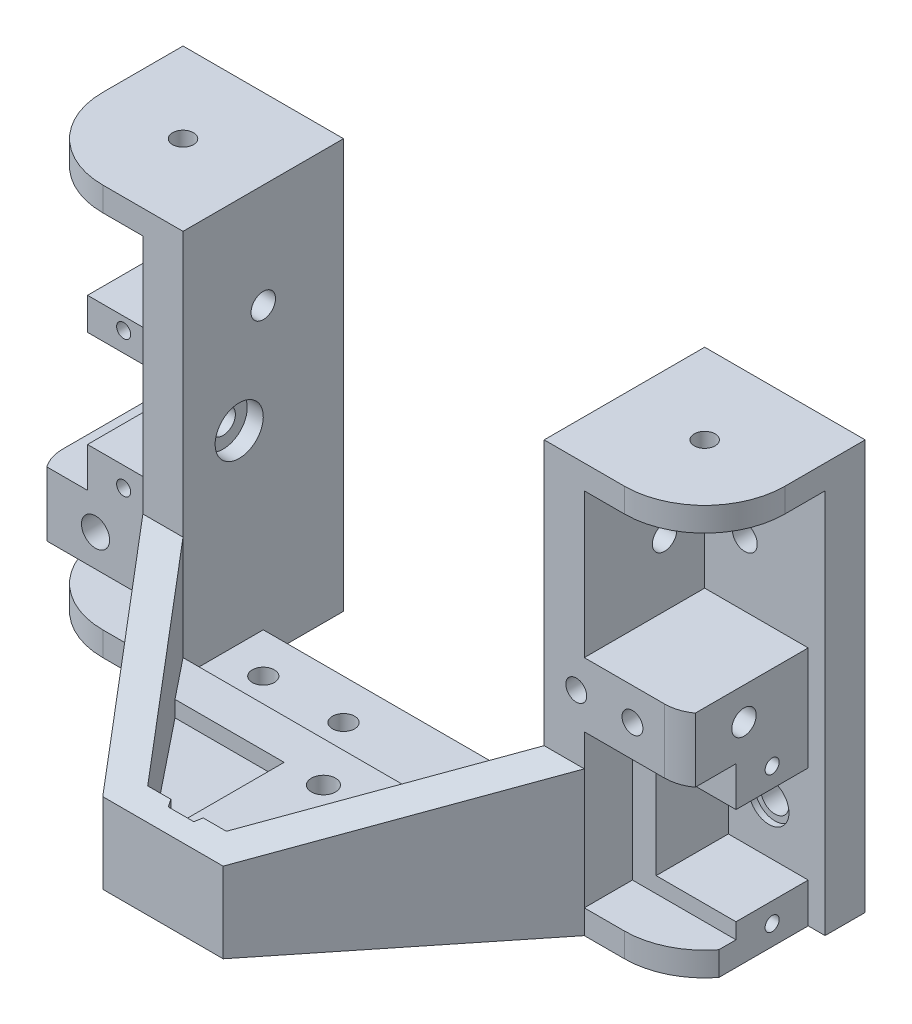
from build123d import *

# Parameters (mm, degrees)
SKETCH1_R                 = 1.75
SKETCH1_R_2               = 1.55
MAIN_FLANGE_DEPTH         = 5
SKETCH2_W                 = 15
SKETCH2_H                 = 45
SKETCH2_R                 = 1.525
SIDE_FLANGE_DEPTH         = 5
SKETCH11_R                = 1.3
BOSS_EXTRUDE3_DEPTH       = 3
BOSS_EXTRUDE4_DEPTH       = 7
SKETCH16_R                = 1.3
TOP_SUPPORT_DEPTH         = 3
SKETCH18_W                = 15
SKETCH18_H                = 8
SKETCH18_R                = 1.525
BOSS_EXTRUDE5_DEPTH       = 15
SKETCH19_W                = 15
SKETCH19_H                = 8
SKETCH19_R                = 1.75
BOSS_EXTRUDE6_DEPTH       = 15
FILLET1_R                 = 5
M3X0_5_TAPPED_HOLE1_D     = 2.6
M3X0_5_TAPPED_HOLE1_DEPTH = 7.5
M3X0_5_TAPPED_HOLE1_TIP   = 0.781118805
M3X0_5_TAPPED_HOLE2_D     = 2.6
M3X0_5_TAPPED_HOLE2_DEPTH = 7.5
M3X0_5_TAPPED_HOLE2_TIP   = 0.781118805
SKETCH24_R                = 2.5
CUT_EXTRUDE1_DEPTH        = 0.75
SKETCH25_R                = 2.5
CUT_EXTRUDE2_DEPTH        = 0.75
SKETCH26_W                = 10
SKETCH26_H                = 2.85
BOSS_EXTRUDE7_DEPTH       = 10
MOTOR_MOUNT_DEPTH         = 9
SKETCH33_W                = 15
SKETCH33_H                = 30
CUT_EXTRUDE6_DEPTH        = 2.1
SKETCH34_R                = 0.875
CUT_EXTRUDE7_DEPTH        = 7
BOSS_EXTRUDE9_DEPTH       = 9
SKETCH36_W                = 15
SKETCH36_H                = 29.05
CUT_EXTRUDE8_DEPTH        = 2.1
SKETCH37_R                = 0.875
CUT_EXTRUDE9_DEPTH        = 7
SKETCH39_W                = 45
SKETCH39_H                = 10
CUT_EXTRUDE11_DEPTH       = 52
SKETCH40_R                = 1.375
MOUNT_HOLES_DEPTH         = 4.0000001
SKETCH41_R                = 3
BEARING_HOLDER_DEPTH      = 2
SKETCH42_R                = 3
CUT_EXTRUDE14_DEPTH       = 2
BOSS_EXTRUDE10_DEPTH      = 3
BOSS_EXTRUDE11_DEPTH      = 15
CUT_EXTRUDE15_DEPTH       = 43.5
CUT_EXTRUDE15_DEPTH_BACK  = 43.5000001
BOSS_EXTRUDE12_DEPTH      = 2
CUT_EXTRUDE16_REACH       = 53
SKETCH48_R                = 1.5
CUT_EXTRUDE17_DEPTH       = 47


with BuildPart() as part:
    # Sketch1 → main flange (new body)
    with BuildSketch(Plane.XY):
        Polygon((-22.5, 7), (0, 7), (22.5, 7), (22.5, 45), (42.5, 45), (42.5, 0), (-42.5, 0), (-42.5, 45), (-22.5, 45), align=None)
        with Locations((35.5, 8)):
            Circle(SKETCH1_R, mode=Mode.SUBTRACT)
        with Locations((-35.5, 8)):
            Circle(SKETCH1_R, mode=Mode.SUBTRACT)
        with Locations((32.5, 35)):
            Circle(SKETCH1_R_2, mode=Mode.SUBTRACT)
        with Locations((-32.5, 35)):
            Circle(SKETCH1_R_2, mode=Mode.SUBTRACT)
    extrude(amount=MAIN_FLANGE_DEPTH)

    # Sketch2 → side flange (add)
    with BuildSketch(Plane(origin=(22.5, 0, 0), x_dir=(0, 0, -1), z_dir=(1, 0, 0))):
        with Locations((-12.5, 22.5)):
            Rectangle(SKETCH2_W, SKETCH2_H)
        with Locations((-13, 23)):
            Circle(SKETCH2_R, mode=Mode.SUBTRACT)
        with Locations((-10, 35)):
            Circle(SKETCH2_R, mode=Mode.SUBTRACT)
    side_flange = extrude(amount=SIDE_FLANGE_DEPTH)

    # Mirror1: side flange across plane
    add(side_flange.mirror(Plane(origin=(0, 0, 0), x_dir=(0, 0, 1), z_dir=(1, 0, 0))))

    # Sketch11 → Boss-Extrude3 (add)
    with BuildSketch(Plane.XZ):
        with BuildLine():
            Line((-42.5, 0), (42.5, 0))
            Line((42.5, 0), (42.5, 10))
            ThreePointArc((42.5, 10), (39.571067812, 17.071067812), (32.5, 20))
            Line((32.5, 20), (-32.5, 20))
            ThreePointArc((-32.5, 20), (-39.571067812, 17.071067812), (-42.5, 10))
            Line((-42.5, 10), (-42.5, 0))
        make_face()
        with Locations((-32.5, 10)):
            Circle(SKETCH11_R, mode=Mode.SUBTRACT)
        with Locations((32.5, 10)):
            Circle(SKETCH11_R, mode=Mode.SUBTRACT)
    extrude(amount=BOSS_EXTRUDE3_DEPTH)

    # Sketch12 → Boss-Extrude4 (add)
    with BuildSketch(Plane(origin=(0, 0, 0), x_dir=(1, 0, 0), z_dir=(0, 1, 0))):
        with BuildLine():
            Line((-4, -3), (-4, 0))
            Line((-4, 0), (4, 0))
            Line((4, 0), (4, -3))
            ThreePointArc((4, -3), (0, -7), (-4, -3))
        make_face()
    extrude(amount=BOSS_EXTRUDE4_DEPTH)

    # Sketch15 → CSK for M3 Flat Head Machine Screw1 (revolve, cut)
    with BuildSketch(Plane(origin=(0, -3, 3), x_dir=(0, 0, -1), z_dir=(1, 0, 0))):
        Polygon((0, 0), (0, 10), (1.8, 10), (1.8, 1.5), (3.15, 0.15), (3.15, 0), align=None)
    revolve(axis=Axis((0, -9.35, 3), (0, 1, 0)), mode=Mode.SUBTRACT)

    # Sketch16 → Top support (add)
    with BuildSketch(Plane(origin=(0, 45, 0), x_dir=(1, 0, 0), z_dir=(0, 1, 0))):
        with BuildLine():
            Line((-42.5, 0), (-22.5, 0))
            Line((-22.5, 0), (-22.5, -20))
            Line((-22.5, -20), (-32.5, -20))
            ThreePointArc((-32.5, -20), (-39.571067812, -17.071067812), (-42.5, -10))
            Line((-42.5, -10), (-42.5, 0))
        make_face()
        with Locations((-32.5, -10)):
            Circle(SKETCH16_R, mode=Mode.SUBTRACT)
        with BuildLine():
            Line((42.5, 0), (42.5, -10))
            ThreePointArc((42.5, -10), (39.571067812, -17.071067812), (32.5, -20))
            Line((32.5, -20), (22.5, -20))
            Line((22.5, -20), (22.5, 0))
            Line((22.5, 0), (42.5, 0))
        make_face()
        with Locations((32.5, -10)):
            Circle(SKETCH16_R, mode=Mode.SUBTRACT)
    extrude(amount=TOP_SUPPORT_DEPTH)

    # Sketch18 → Boss-Extrude5 (add)
    with BuildSketch(Plane(origin=(27.5, 0, 0), x_dir=(0, 0, -1), z_dir=(1, 0, 0))):
        with Locations((-12.5, 23)):
            Rectangle(SKETCH18_W, SKETCH18_H)
        with Locations((-13, 23)):
            Circle(SKETCH18_R, mode=Mode.SUBTRACT)
    extrude(amount=BOSS_EXTRUDE5_DEPTH)

    # Sketch19 → Boss-Extrude6 (add)
    with BuildSketch(Plane.XY.offset(5)):
        with Locations((-35, 8)):
            Rectangle(SKETCH19_W, SKETCH19_H)
        with Locations((-35.5, 8)):
            Circle(SKETCH19_R, mode=Mode.SUBTRACT)
    extrude(amount=BOSS_EXTRUDE6_DEPTH)

    # Fillet1
    fillet1_edges = [part.edges().sort_by_distance(p)[0] for p in [
        (42.5, 23, 20),
        (-42.5, 8, 20),
    ]]
    fillet(fillet1_edges, radius=FILLET1_R)

    # M3x0.5 Tapped Hole1
    with Locations(Plane.ZY.offset(42.5)):
        with Locations((11, 8), (4, 8)):
            Hole(M3X0_5_TAPPED_HOLE1_D / 2, depth=M3X0_5_TAPPED_HOLE1_DEPTH)
            with Locations((0, 0, -(M3X0_5_TAPPED_HOLE1_DEPTH + M3X0_5_TAPPED_HOLE1_TIP / 2))):  # 118° drill point
                Cone(0, M3X0_5_TAPPED_HOLE1_D / 2, M3X0_5_TAPPED_HOLE1_TIP, mode=Mode.SUBTRACT)

    # M3x0.5 Tapped Hole2
    with Locations(Plane.XY.offset(20)):
        with Locations((33.5, 23), (26.5, 23)):
            Hole(M3X0_5_TAPPED_HOLE2_D / 2, depth=M3X0_5_TAPPED_HOLE2_DEPTH)
            with Locations((0, 0, -(M3X0_5_TAPPED_HOLE2_DEPTH + M3X0_5_TAPPED_HOLE2_TIP / 2))):  # 118° drill point
                Cone(0, M3X0_5_TAPPED_HOLE2_D / 2, M3X0_5_TAPPED_HOLE2_TIP, mode=Mode.SUBTRACT)

    # Sketch24 → Cut-Extrude1 (cut)
    with BuildSketch(Plane.XY.offset(5)):
        with Locations((35.5, 8)):
            Circle(SKETCH24_R)
    extrude(amount=-CUT_EXTRUDE1_DEPTH, mode=Mode.SUBTRACT)

    # Sketch25 → Cut-Extrude2 (cut)
    with BuildSketch(Plane.ZY.offset(27.5)):
        with Locations((13, 23)):
            Circle(SKETCH25_R)
    extrude(amount=-CUT_EXTRUDE2_DEPTH, mode=Mode.SUBTRACT)

    # Sketch26 → Boss-Extrude7 (add)
    with BuildSketch(Plane(origin=(0, 7, 0), x_dir=(1, 0, 0), z_dir=(0, 1, 0))):
        with Locations((-10.2, -1.425)):
            Rectangle(SKETCH26_W, SKETCH26_H)
        with Locations((10.2, -1.425)):
            Rectangle(SKETCH26_W, SKETCH26_H)
    extrude(amount=BOSS_EXTRUDE7_DEPTH)

    # Sketch32 → Motor mount (add)
    with BuildSketch(Plane.XY.offset(5)):
        Polygon((40.4, 14.05), (30.45, 14.05), (30.45, 1.95), (40.4, 1.95), (40.4, 0), (27.5, 0), (27.5, 19), (40.4, 19), align=None)
    extrude(amount=MOTOR_MOUNT_DEPTH)

    # Sketch33 → Cut-Extrude6 (cut)
    with BuildSketch(Plane(origin=(42.5, 0, 0), x_dir=(0, 0, -1), z_dir=(1, 0, 0))):
        with Locations((-12.5, 12)):
            Rectangle(SKETCH33_W, SKETCH33_H)
    extrude(amount=-CUT_EXTRUDE6_DEPTH, mode=Mode.SUBTRACT)

    # Sketch34 → Cut-Extrude7 (cut)
    with BuildSketch(Plane(origin=(40.4, 0, 0), x_dir=(0, 0, -1), z_dir=(1, 0, 0))):
        with Locations((-9.5, 16.5)):
            Circle(SKETCH34_R)
        with Locations((-9.5, -0.5)):
            Circle(SKETCH34_R)
    extrude(amount=-CUT_EXTRUDE7_DEPTH, mode=Mode.SUBTRACT)

    # Sketch35 → Boss-Extrude9 (add)
    with BuildSketch(Plane.ZY.offset(27.5)):
        Polygon((20, 29.05), (7.95, 29.05), (7.95, 16.95), (20, 16.95), (20, 12), (5, 12), (5, 33.05), (20, 33.05), align=None)
    extrude(amount=BOSS_EXTRUDE9_DEPTH)

    # Sketch36 → Cut-Extrude8 (cut)
    with BuildSketch(Plane.XY.offset(20)):
        with Locations((-35, 18.525)):
            Rectangle(SKETCH36_W, SKETCH36_H)
    extrude(amount=-CUT_EXTRUDE8_DEPTH, mode=Mode.SUBTRACT)

    # Sketch37 → Cut-Extrude9 (cut)
    with BuildSketch(Plane.XY.offset(17.9)):
        with Locations((-32, 31.5)):
            Circle(SKETCH37_R)
        with Locations((-32, 14.5)):
            Circle(SKETCH37_R)
    extrude(amount=-CUT_EXTRUDE9_DEPTH, mode=Mode.SUBTRACT)

    # Sketch39 → Cut-Extrude11 (cut, through all)
    with BuildSketch(Plane.XZ.offset(3)):
        with Locations((0, 5)):
            Rectangle(SKETCH39_W, SKETCH39_H)
    extrude(amount=-CUT_EXTRUDE11_DEPTH, mode=Mode.SUBTRACT)

    # Sketch40 → Mount Holes (cut, through all)
    with BuildSketch(Plane(origin=(0, 0, 0), x_dir=(1, 0, 0), z_dir=(0, 1, 0))):
        with Locations((-17.5, -15)):
            Circle(SKETCH40_R)
        with Locations((-7.5, -15)):
            Circle(SKETCH40_R)
        with Locations((7.5, -15)):
            Circle(SKETCH40_R)
        with Locations((17.5, -15)):
            Circle(SKETCH40_R)
    extrude(amount=-MOUNT_HOLES_DEPTH, mode=Mode.SUBTRACT)

    # Sketch41 → Bearing Holder (cut)
    with BuildSketch(Plane(origin=(-22.5, 0, 0), x_dir=(0, 0, -1), z_dir=(1, 0, 0))):
        with Locations((-13, 23)):
            Circle(SKETCH41_R)
    extrude(amount=-BEARING_HOLDER_DEPTH, mode=Mode.SUBTRACT)

    # Sketch42 → Cut-Extrude14 (cut)
    with BuildSketch(Plane(origin=(0, 0, 0), x_dir=(-1, 0, 0), z_dir=(0, 0, -1))):
        with Locations((-35.5, 8)):
            Circle(SKETCH42_R)
    extrude(amount=-CUT_EXTRUDE14_DEPTH, mode=Mode.SUBTRACT)

    # Sketch44 → Boss-Extrude10 (add)
    with BuildSketch(Plane.XZ.offset(3)):
        Polygon((-7.5, 45), (7.5, 45), (27.5, 20), (-27.5, 20), align=None)
    extrude(amount=-BOSS_EXTRUDE10_DEPTH)

    # Sketch45 → Boss-Extrude11 (add)
    with BuildSketch(Plane(origin=(0, 0, 0), x_dir=(1, 0, 0), z_dir=(0, 1, 0))):
        Polygon((-22.5, -20), (-27.5, -20), (-7.5, -45), (7.5, -45), (27.5, -20), (22.5, -20), (4.9, -42), (-4.9, -42), align=None)
    extrude(amount=BOSS_EXTRUDE11_DEPTH)

    # Sketch46 → Cut-Extrude15 (cut, two sides)
    with BuildSketch(Plane(origin=(0, 0, 0), x_dir=(0, 0, -1), z_dir=(1, 0, 0))) as cut_extrude15_sk:
        Polygon((-20, 15), (-45, 7), (-45, 15), align=None)
    extrude(amount=CUT_EXTRUDE15_DEPTH, mode=Mode.SUBTRACT)
    extrude(cut_extrude15_sk.sketch, amount=-CUT_EXTRUDE15_DEPTH_BACK, mode=Mode.SUBTRACT)

    # Sketch50 → Boss-Extrude12 (add)
    with BuildSketch(Plane(origin=(0, 0, 0), x_dir=(1, 0, 0), z_dir=(0, 1, 0))):
        Polygon((-22.5, -20), (22.5, -20), (18.5, -25), (4.9, -25), (4.9, -42), (-4.9, -42), (-4.9, -25), (-18.5, -25), align=None)
    extrude(amount=BOSS_EXTRUDE12_DEPTH)

    # Sketch48 → Cut-Extrude16 (cut, up to next)
    with BuildSketch(Plane.XZ.offset(3), mode=Mode.PRIVATE) as cut_extrude16_sk1:
        with Locations((0, 40)):
            Circle(SKETCH48_R)
    cut_extrude16_tool1 = extrude(cut_extrude16_sk1.sketch, amount=-CUT_EXTRUDE16_REACH, mode=Mode.PRIVATE) & part.part
    add(cut_extrude16_tool1.solids().sort_by_distance((0, -3, 40))[0], mode=Mode.SUBTRACT)
    # Sketch48 → Cut-Extrude16 (cut, up to next)
    with BuildSketch(Plane.XZ.offset(3), mode=Mode.PRIVATE) as cut_extrude16_sk2:
        with Locations((0, 25)):
            Circle(SKETCH48_R)
    cut_extrude16_tool2 = extrude(cut_extrude16_sk2.sketch, amount=-CUT_EXTRUDE16_REACH, mode=Mode.PRIVATE) & part.part
    add(cut_extrude16_tool2.solids().sort_by_distance((0, -3, 25))[0], mode=Mode.SUBTRACT)

    # Sketch51 → Cut-Extrude17 (cut, through all)
    with BuildSketch(Plane(origin=(0, 2, 0), x_dir=(1, 0, 0), z_dir=(0, 1, 0))):
        Polygon((3.175426481, -40), (1.58771324, -37.25), (-1.58771324, -37.25), (-3.175426481, -40), (-1.58771324, -42.75), (1.58771324, -42.75), align=None)
    extrude(amount=CUT_EXTRUDE17_DEPTH, mode=Mode.SUBTRACT)


solid = part.part
